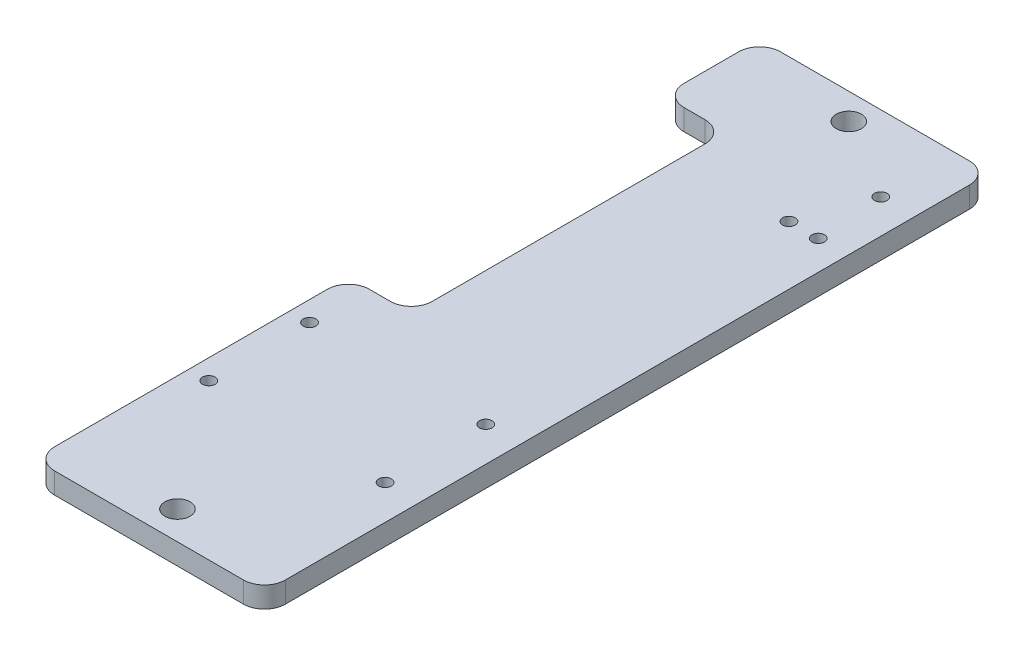
from build123d import *

# Parameters (mm, degrees)
SKETCH1_W           = 200
SKETCH1_H           = 200
BOSS_EXTRUDE1_DEPTH = 5
SKETCH2_W           = 100
SKETCH2_H           = 100
CUT_EXTRUDE1_DEPTH  = 10
FILLET1_R           = 10
FILLET2_R           = 10
SKETCH3_R           = 3
CUT_EXTRUDE2_DEPTH  = 10
SKETCH4_R           = 1.5
CUT_EXTRUDE3_DEPTH  = 10
SKETCH5_W           = 210
SKETCH5_H           = 210
BOSS_EXTRUDE2_DEPTH = 5
FILLET3_R           = 10
CIRPATTERN1_COUNT   = 4
SKETCH6_OUTSIDE_W   = 271.406
SKETCH6_OUTSIDE_H   = 271.406
SKETCH6_OUTSIDE_W_2 = 55
SKETCH6_OUTSIDE_H_2 = 132
CUT_EXTRUDE4_DEPTH  = 10
SKETCH8_W           = 55
SKETCH8_H           = 30
BOSS_EXTRUDE3_DEPTH = 5
SKETCH9_R           = 3
CUT_EXTRUDE6_DEPTH  = 5
SKETCH11_W          = 55
SKETCH11_H          = 19
CUT_EXTRUDE7_DEPTH  = 39
FILLET6_R           = 5
SKETCH12_W          = 15
SKETCH12_H          = 75
CUT_EXTRUDE8_DEPTH  = 10
FILLET7_R           = 5


with BuildPart() as part:
    # Sketch1 → Boss-Extrude1 (new body)
    with BuildSketch(Plane(origin=(0, 0, 0), x_dir=(1, 0, 0), z_dir=(0, 1, 0))):
        with Locations((100, 100)):
            Rectangle(SKETCH1_W, SKETCH1_H)
    extrude(amount=BOSS_EXTRUDE1_DEPTH)

    # Sketch2 → Cut-Extrude1 (cut)
    with BuildSketch(Plane(origin=(0, 5, 0), x_dir=(1, 0, 0), z_dir=(0, 1, 0))):
        with Locations((100, 100)):
            Rectangle(SKETCH2_W, SKETCH2_H)
    extrude(amount=-CUT_EXTRUDE1_DEPTH, mode=Mode.SUBTRACT)

    # Fillet1
    fillet1_edges = [part.edges().sort_by_distance(p)[0] for p in [
        (50, 2.5, -50),
        (150, 2.5, -50),
        (150, 2.5, -150),
        (50, 2.5, -150),
    ]]
    fillet(fillet1_edges, radius=FILLET1_R)

    # Fillet2
    fillet2_edges = [part.edges().sort_by_distance(p)[0] for p in [
        (200, 2.5, 0),
        (0, 2.5, 0),
        (0, 2.5, -200),
        (200, 2.5, -200),
    ]]
    fillet(fillet2_edges, radius=FILLET2_R)

    # Sketch3 → Cut-Extrude2 (cut)
    with BuildSketch(Plane(origin=(0, 5, 0), x_dir=(1, 0, 0), z_dir=(0, 1, 0))):
        with Locations((10, 190)):
            Circle(SKETCH3_R)
        with Locations((190, 190)):
            Circle(SKETCH3_R)
        with Locations((190, 10)):
            Circle(SKETCH3_R)
        with Locations((10, 10)):
            Circle(SKETCH3_R)
    extrude(amount=-CUT_EXTRUDE2_DEPTH, mode=Mode.SUBTRACT)

    # Sketch4 → Cut-Extrude3 (cut)
    with BuildSketch(Plane(origin=(0, 5, 0), x_dir=(1, 0, 0), z_dir=(0, 1, 0))):
        with Locations((198, 126)):
            Circle(SKETCH4_R)
        with Locations((191, 126)):
            Circle(SKETCH4_R)
        with Locations((196.89, 142)):
            Circle(SKETCH4_R)
        with Locations((154.75, 48)):
            Circle(SKETCH4_R)
        with Locations((196.75, 48)):
            Circle(SKETCH4_R)
        with Locations((196.75, 24)):
            Circle(SKETCH4_R)
        with Locations((154.75, 24)):
            Circle(SKETCH4_R)
        with Locations((242.150033952, -166.330778193)):
            Circle(SKETCH4_R)
        with Locations((285.400033952, -64.330778193)):
            Circle(SKETCH4_R)
        with Locations((242.150033952, -142.330778193)):
            Circle(SKETCH4_R)
        with Locations((284.290033952, -48.330778193)):
            Circle(SKETCH4_R)
        with Locations((284.150033952, -142.330778193)):
            Circle(SKETCH4_R)
        with Locations((284.150033952, -166.330778193)):
            Circle(SKETCH4_R)
        with Locations((278.400033952, -64.330778193)):
            Circle(SKETCH4_R)
    cut_extrude3 = extrude(amount=-CUT_EXTRUDE3_DEPTH, mode=Mode.SUBTRACT)

    # Sketch5 → Boss-Extrude2 (add)
    with BuildSketch(Plane(origin=(0, 5, 0), x_dir=(1, 0, 0), z_dir=(0, 1, 0))):
        with Locations((100, 100)):
            Rectangle(SKETCH5_W, SKETCH5_H)
        with BuildLine():
            Line((0, 190), (0, 10))
            ThreePointArc((0, 10), (2.928932188, 2.928932188), (10, 0))
            Line((10, 0), (190, 0))
            ThreePointArc((190, 0), (197.071067812, 2.928932188), (200, 10))
            Line((200, 10), (200, 190))
            ThreePointArc((200, 190), (197.071067812, 197.071067812), (190, 200))
            Line((190, 200), (10, 200))
            ThreePointArc((10, 200), (2.928932188, 197.071067812), (0, 190))
        make_face(mode=Mode.SUBTRACT)
    extrude(amount=-BOSS_EXTRUDE2_DEPTH)

    # Fillet3
    fillet3_edges = [part.edges().sort_by_distance(p)[0] for p in [
        (205, 2.5, -205),
        (-5, 2.5, -205),
        (-5, 2.5, 5),
        (205, 2.5, 5),
    ]]
    fillet(fillet3_edges, radius=FILLET3_R)

    # CirPattern1: Cut-Extrude3 ×4 about axis
    cirpattern1_axis = Axis((100, 5.25, -100), (0, -1, 0))
    for i in range(1, CIRPATTERN1_COUNT):
        add(cut_extrude3.rotate(cirpattern1_axis, i * 360 / CIRPATTERN1_COUNT), mode=Mode.SUBTRACT)

    # Sketch6 outside → Cut-Extrude4 (cut)
    with BuildSketch(Plane(origin=(0, 5, 0), x_dir=(1, 0, 0), z_dir=(0, 1, 0))):
        with Locations((100, 100)):
            Rectangle(SKETCH6_OUTSIDE_W, SKETCH6_OUTSIDE_H)
        with Locations((177.5, 83)):
            Rectangle(SKETCH6_OUTSIDE_W_2, SKETCH6_OUTSIDE_H_2, mode=Mode.SUBTRACT)
    extrude(amount=-CUT_EXTRUDE4_DEPTH, mode=Mode.SUBTRACT)

    # Sketch8 → Boss-Extrude3 (add)
    with BuildSketch(Plane(origin=(0, 5, 0), x_dir=(1, 0, 0), z_dir=(0, 1, 0))):
        with Locations((177.5, 2)):
            Rectangle(SKETCH8_W, SKETCH8_H)
        with Locations((177.5, 164)):
            Rectangle(SKETCH8_W, SKETCH8_H)
    extrude(amount=-BOSS_EXTRUDE3_DEPTH)

    # Sketch9 → Cut-Extrude6 (cut)
    with BuildSketch(Plane(origin=(0, 5, 0), x_dir=(1, 0, 0), z_dir=(0, 1, 0))):
        with Locations((177.5, 153.77)):
            Circle(SKETCH9_R)
        with Locations((177.5, -6.23)):
            Circle(SKETCH9_R)
    extrude(amount=-CUT_EXTRUDE6_DEPTH, mode=Mode.SUBTRACT)

    # Sketch11 → Cut-Extrude7 (cut)
    with BuildSketch(Plane(origin=(0, 5, 0), x_dir=(1, 0, 0), z_dir=(0, 1, 0))):
        with Locations((177.5, 169.5)):
            Rectangle(SKETCH11_W, SKETCH11_H)
    extrude(amount=-CUT_EXTRUDE7_DEPTH, mode=Mode.SUBTRACT)

    # Fillet6
    fillet6_edges = [part.edges().sort_by_distance(p)[0] for p in [
        (205, 2.5, 13),
        (150, 2.5, 13),
        (150, 2.5, -160),
        (205, 2.5, -160),
    ]]
    fillet(fillet6_edges, radius=FILLET6_R)

    # Sketch12 → Cut-Extrude8 (cut)
    with BuildSketch(Plane(origin=(0, 5, 0), x_dir=(1, 0, 0), z_dir=(0, 1, 0))):
        with Locations((157.5, 99.5)):
            Rectangle(SKETCH12_W, SKETCH12_H)
    extrude(amount=-CUT_EXTRUDE8_DEPTH, mode=Mode.SUBTRACT)

    # Fillet7
    fillet7_edges = [part.edges().sort_by_distance(p)[0] for p in [
        (165, 2.5, -137),
        (165, 2.5, -62),
        (150, 2.5, -62),
        (150, 2.5, -137),
    ]]
    fillet(fillet7_edges, radius=FILLET7_R)


solid = part.part
